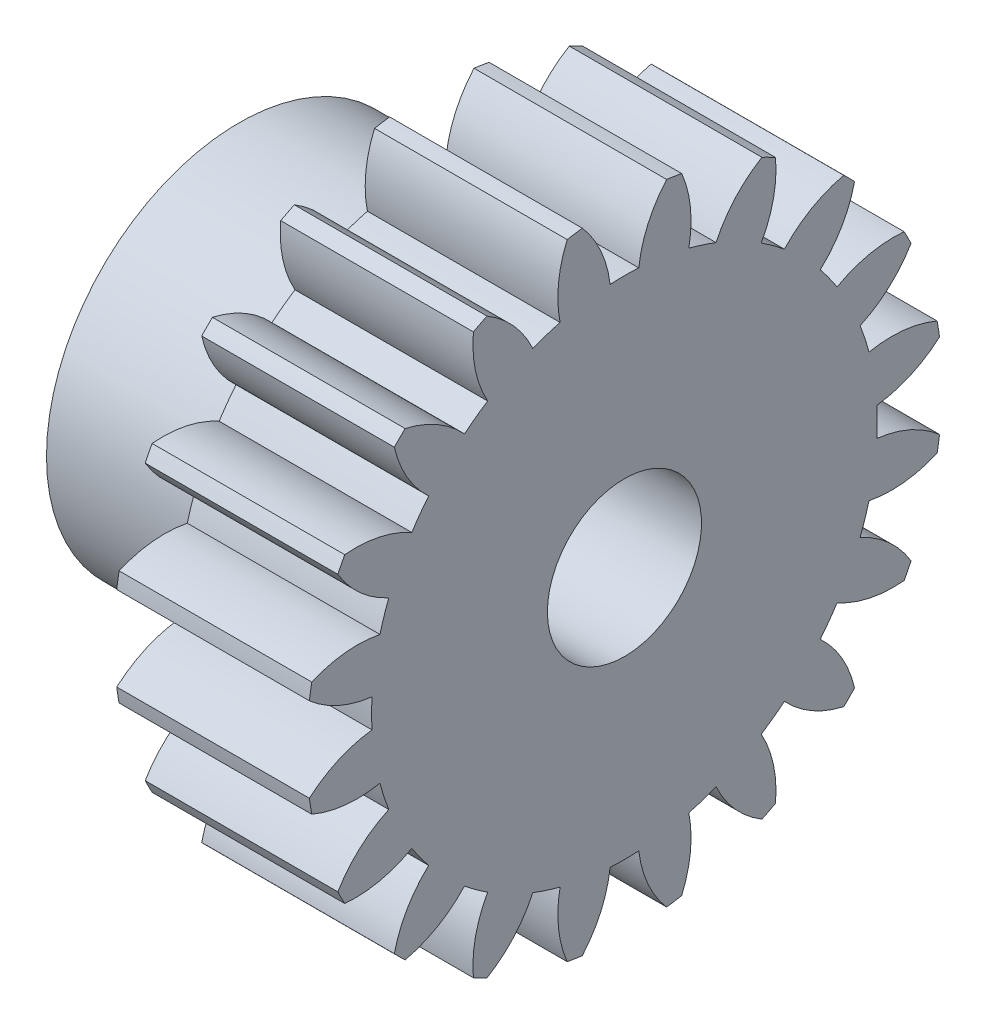
from build123d import *

# Parameters (mm, degrees)
BASPROSKE_W        = 10
BASPROSKE_H        = 16.5
TOOTHCUT_DEPTH     = 26.38700455
TEETHCUTS_COUNT    = 20
TEETHCUTS_ANGLE    = 342
HUBNEAONESKE_R     = 10
HUBNEARONE_DEPTH   = 10.0000508
BORSKE_R           = 4
BORE_DEPTH         = 20.0000508
CUT_EXTRUDE1_DEPTH = 5


with BuildPart() as part:
    # BasProSke → Base-Revolve (revolve)
    with BuildSketch(Plane(origin=(0, 0, 0), x_dir=(1, 0, 0), z_dir=(0, 1, 0)), mode=Mode.PRIVATE) as base_revolve_sk:
        with Locations((5, 8.25)):
            Rectangle(BASPROSKE_W, BASPROSKE_H)
    revolve(base_revolve_sk.sketch.rotate(Axis((-10, 0, 0), (1, 0, 0)), 180), axis=Axis((-10, 0, 0), (1, 0, 0)))

    # TooCutSke → ToothCut (cut, through all)
    with BuildSketch(Plane(origin=(0, 0, 0), x_dir=(0, 0, -1), z_dir=(1, 0, 0))):
        with BuildLine():
            ThreePointArc((0.74381438, 13.102904875), (0, 13.124), (-0.74381438, 13.102904875))
            ThreePointArc((-0.74381438, 13.102904875), (-1.226473103, 14.852072512), (-2.209965745, 16.376962373))
            ThreePointArc((-2.209965745, 16.376962373), (0, 16.5254), (2.209965745, 16.376962373))
            ThreePointArc((2.209965745, 16.376962373), (1.226473103, 14.852072512), (0.74381438, 13.102904875))
        make_face()
    toothcut = extrude(amount=TOOTHCUT_DEPTH, mode=Mode.SUBTRACT)

    # TeethCuts: ToothCut ×20 about axis
    teethcuts_axis = Axis((-10, 0, 0), (1, 0, 0))
    for i in range(1, TEETHCUTS_COUNT):
        add(toothcut.rotate(teethcuts_axis, i * TEETHCUTS_ANGLE / (TEETHCUTS_COUNT - 1)), mode=Mode.SUBTRACT)

    # HubNeaOneSke → HubNearOne (add)
    with BuildSketch(Plane.ZY):
        with Locations(Location((0, 0, 0), (0, 0, 180))):
            Circle(HUBNEAONESKE_R)
    extrude(amount=HUBNEARONE_DEPTH)

    # BorSke → Bore (cut, symmetric)
    with BuildSketch(Plane(origin=(0, 0, 0), x_dir=(0, 0, -1), z_dir=(1, 0, 0))):
        with Locations(Location((0, 0, 0), (0, 0, 180))):
            Circle(BORSKE_R)
    extrude(amount=BORE_DEPTH, both=True, mode=Mode.SUBTRACT)

    # Sketch2 → Cut-Extrude1 (cut)
    with BuildSketch(Plane.ZY.offset(10.0000508)):
        with BuildLine():
            Line((3.12475599, -2), (7.445, -2))
            ThreePointArc((7.445, -2), (9.445, 0), (7.445, 2))
            Line((7.445, 2), (3.12475599, 2))
            ThreePointArc((3.12475599, 2), (0, 3.71), (-3.12475599, 2))
            Line((-3.12475599, 2), (-7.445, 2))
            ThreePointArc((-7.445, 2), (-9.445, 0), (-7.445, -2))
            Line((-7.445, -2), (-3.12475599, -2))
            ThreePointArc((-3.12475599, -2), (0, -3.71), (3.12475599, -2))
        make_face()
    extrude(amount=-CUT_EXTRUDE1_DEPTH, mode=Mode.SUBTRACT)


solid = part.part
